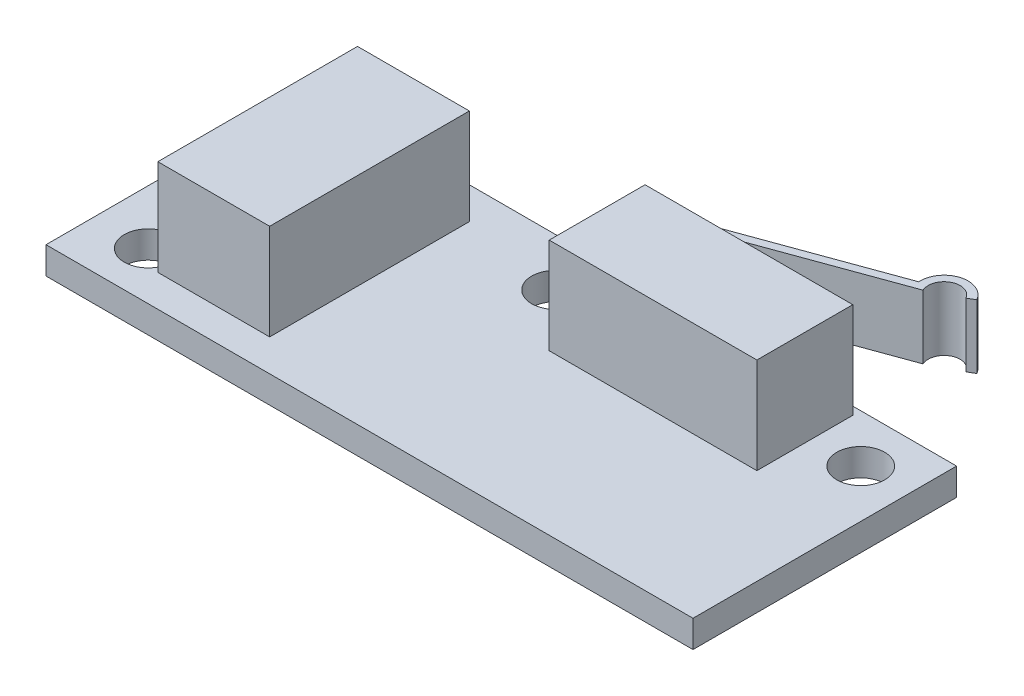
from build123d import *

# Parameters (mm, degrees)
SKETCH1_W           = 40.5
SKETCH1_H           = 16.5
SKETCH1_R           = 1.5
BOSS_EXTRUDE1_DEPTH = 1.7
SKETCH2_W           = 7
SKETCH2_H           = 12.5
BOSS_EXTRUDE2_DEPTH = 6
SHELL1_T            = -0.5
BOSS_EXTRUDE3_DEPTH = 6
SKETCH4_W           = 14.620237932
SKETCH4_H           = 5.897683247
CUT_EXTRUDE1_DEPTH  = 1
SKETCH5_W           = 13.246499222
SKETCH5_H           = 5.397683247
CUT_EXTRUDE2_DEPTH  = 1


with BuildPart() as part:
    # Sketch1 → Boss-Extrude1 (new body)
    with BuildSketch(Plane(origin=(0, 0, 0), x_dir=(1, 0, 0), z_dir=(0, 1, 0))):
        with Locations((20.25, 8.25)):
            Rectangle(SKETCH1_W, SKETCH1_H)
        with Locations((3.4, 3)):
            Circle(SKETCH1_R, mode=Mode.SUBTRACT)
        with Locations((3.4, 13.5)):
            Circle(SKETCH1_R, mode=Mode.SUBTRACT)
        with Locations((18.4, 13.5)):
            Circle(SKETCH1_R, mode=Mode.SUBTRACT)
        with Locations((37.5, 13.5)):
            Circle(SKETCH1_R, mode=Mode.SUBTRACT)
    extrude(amount=BOSS_EXTRUDE1_DEPTH)

    # Sketch3 → Boss-Extrude3 (add)
    with BuildSketch(Plane(origin=(0, 1.7, 0), x_dir=(1, 0, 0), z_dir=(0, 1, 0))):
        with BuildLine():
            Line((21.5, 16), (21.5, 10))
            Line((21.5, 10), (34.5, 10))
            Line((34.5, 10), (34.5, 16))
            Line((34.5, 16), (23.9619022, 16))
            Line((23.9619022, 16), (34.910364087, 19.984914238))
            ThreePointArc((34.910364087, 19.984914238), (35.364265687, 21.287183777), (36.68722523, 20.897683247))
            Line((36.68722523, 20.897683247), (37.120237932, 21.147683247))
            ThreePointArc((37.120237932, 21.147683247), (35.387719987, 21.833682979), (34.324150839, 20.303638951))
            Line((34.324150839, 20.303638951), (22.5, 16))
            Line((22.5, 16), (21.5, 16))
        make_face()
    extrude(amount=BOSS_EXTRUDE3_DEPTH)

    # Sketch4 → Cut-Extrude1 (cut)
    with BuildSketch(Plane(origin=(0, 7.7, 0), x_dir=(1, 0, 0), z_dir=(0, 1, 0))):
        with Locations((29.810118966, 18.948841624)):
            Rectangle(SKETCH4_W, SKETCH4_H)
    extrude(amount=-CUT_EXTRUDE1_DEPTH, mode=Mode.SUBTRACT)

    # Sketch5 → Cut-Extrude2 (cut)
    with BuildSketch(Plane.XZ.offset(-1.7)):
        with Locations((30.496988321, -19.198841624)):
            Rectangle(SKETCH5_W, SKETCH5_H)
    extrude(amount=-CUT_EXTRUDE2_DEPTH, mode=Mode.SUBTRACT)


with BuildPart() as body_2:
    # Sketch2 → Boss-Extrude2 (new body)
    with BuildSketch(Plane(origin=(0, 1.7, 0), x_dir=(1, 0, 0), z_dir=(0, 1, 0))):
        with Locations((8.5, 8.25)):
            Rectangle(SKETCH2_W, SKETCH2_H)
    extrude(amount=BOSS_EXTRUDE2_DEPTH)

    # Shell1
    shell1_openings = [body_2.faces().sort_by_distance(p)[0] for p in [
        (5, 4.7, -8.25),
    ]]
    offset(amount=SHELL1_T, openings=shell1_openings, kind=Kind.INTERSECTION)


solid = Compound([part.part, body_2.part])
